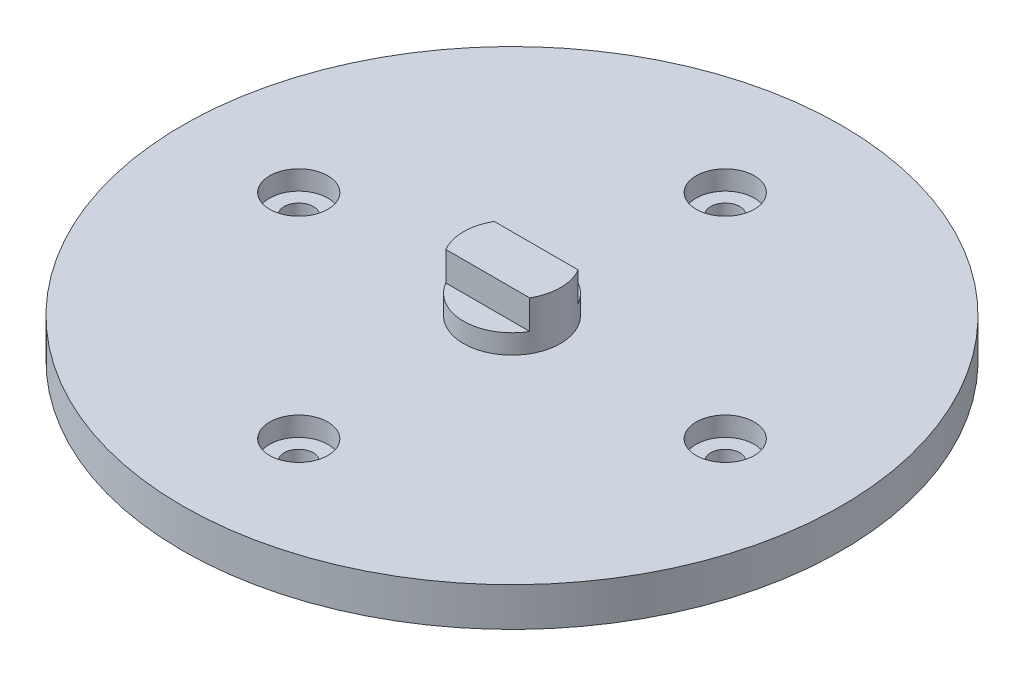
from build123d import *
from build123d.topology import SkipClean

# Parameters (mm, degrees)
SKETCH_1_R      = 34
SKETCH_1_R_2    = 3
EXTRUDE_1_DEPTH = 4
SKETCH_1_3_R    = 3
SKETCH_1_3_R_2  = 1.5
EXTRUDE_2_DEPTH = 2
SKETCH_2_R      = 5
EXTRUDE_3_DEPTH = 2
EXTRUDE_4_DEPTH = 3


with BuildPart() as part:
    # 草图1 → 凸台-拉伸1 (new body)
    with BuildSketch(Plane(origin=(0, 0, 0), x_dir=(1, 0, 0), z_dir=(0, 1, 0))):
        Circle(SKETCH_1_R)
        with Locations((-22, 0)):
            Circle(SKETCH_1_R_2, mode=Mode.SUBTRACT)
        with Locations((0, -22)):
            Circle(SKETCH_1_R_2, mode=Mode.SUBTRACT)
        with Locations((22, 0)):
            Circle(SKETCH_1_R_2, mode=Mode.SUBTRACT)
        with Locations((0, 22)):
            Circle(SKETCH_1_R_2, mode=Mode.SUBTRACT)
    extrude(amount=EXTRUDE_1_DEPTH)

    # 草图1<3> → 凸台-拉伸2 (add)
    # profile 1 of 4: a face of its own
    with BuildSketch(Plane(origin=(0, 0, 0), x_dir=(1, 0, 0), z_dir=(0, 1, 0))):
        with Locations((0, 22)):
            Circle(SKETCH_1_3_R)
        with Locations((0, 22)):
            Circle(SKETCH_1_3_R_2, mode=Mode.SUBTRACT)
    # profile 2 of 4: a face of its own
    with BuildSketch(Plane(origin=(0, 0, 0), x_dir=(1, 0, 0), z_dir=(0, 1, 0))):
        with Locations((22, 0)):
            Circle(SKETCH_1_3_R)
        with Locations((22, 0)):
            Circle(SKETCH_1_3_R_2, mode=Mode.SUBTRACT)
    # profile 3 of 4: a face of its own
    with BuildSketch(Plane(origin=(0, 0, 0), x_dir=(1, 0, 0), z_dir=(0, 1, 0))):
        with Locations((0, -22)):
            Circle(SKETCH_1_3_R)
        with Locations((0, -22)):
            Circle(SKETCH_1_3_R_2, mode=Mode.SUBTRACT)
    # profile 4 of 4: a face of its own
    with BuildSketch(Plane(origin=(0, 0, 0), x_dir=(1, 0, 0), z_dir=(0, 1, 0))):
        with Locations((-22, 0)):
            Circle(SKETCH_1_3_R)
        with Locations((-22, 0)):
            Circle(SKETCH_1_3_R_2, mode=Mode.SUBTRACT)
    extrude(amount=EXTRUDE_2_DEPTH)

    # 草图2 → 凸台-拉伸3 (add)
    with BuildSketch(Plane(origin=(0, 4, 0), x_dir=(1, 0, 0), z_dir=(0, 1, 0))):
        Circle(SKETCH_2_R)
    extrude(amount=EXTRUDE_3_DEPTH)

    # 草图3 → 凸台-拉伸4 (add)
    with SkipClean():  # the faces are left unmerged after this step: merging them gives an invalid solid
        with BuildSketch(Plane(origin=(0, 6, 0), x_dir=(1, 0, 0), z_dir=(0, 1, 0))):
            with BuildLine():
                Line((-4.330127019, 2.5), (4.330127019, 2.5))
                ThreePointArc((4.330127019, 2.5), (5, 0), (4.330127019, -2.5))
                Line((4.330127019, -2.5), (-4.330127019, -2.5))
                ThreePointArc((-4.330127019, -2.5), (-5, 0), (-4.330127019, 2.5))
            make_face()
        extrude(amount=EXTRUDE_4_DEPTH)


solid = part.part
